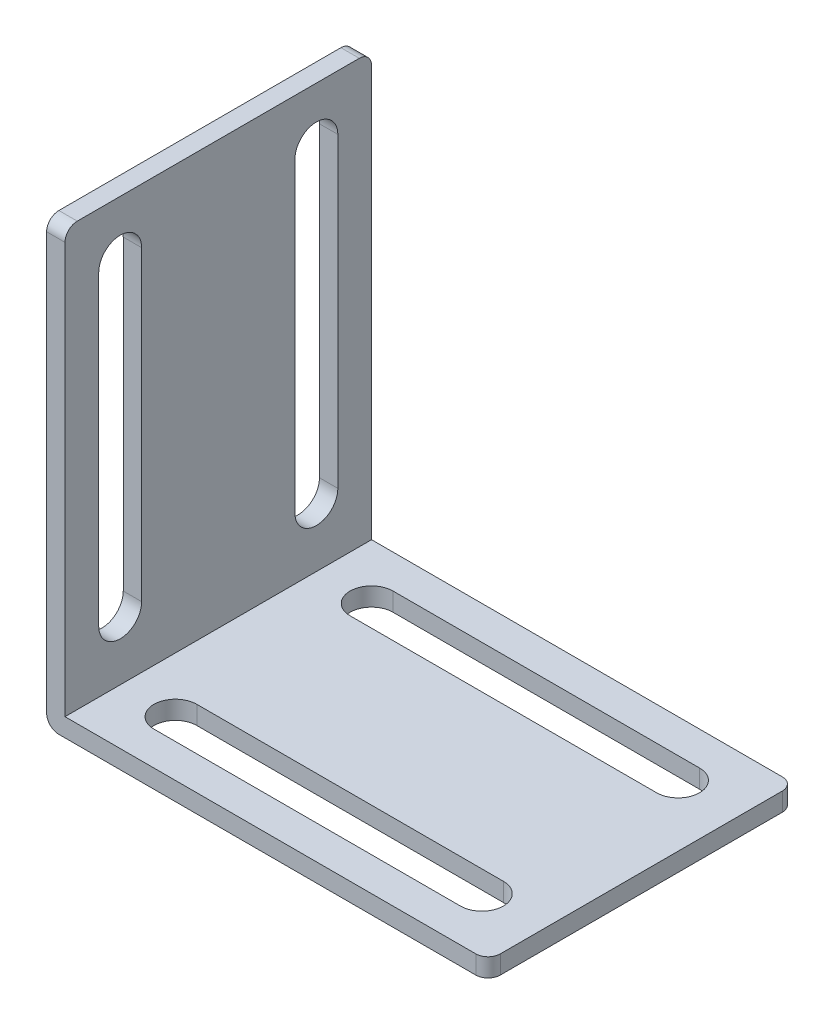
from build123d import *

# Parameters (mm, degrees)
SKETCH1_W           = 36
SKETCH1_H           = 25
BOSS_EXTRUDE1_DEPTH = 36
SKETCH2_W           = 34.5
SKETCH2_H           = 25
CUT_EXTRUDE1_DEPTH  = 34.5
FILLET1_R           = 1
CUT_EXTRUDE2_DEPTH  = 1.5
CUT_EXTRUDE3_DEPTH  = 1.5


with BuildPart() as part:
    # Sketch1 → Boss-Extrude1 (new body)
    with BuildSketch(Plane(origin=(0, 0, 0), x_dir=(1, 0, 0), z_dir=(0, 1, 0))):
        with Locations((18, 12.5)):
            Rectangle(SKETCH1_W, SKETCH1_H)
    extrude(amount=BOSS_EXTRUDE1_DEPTH)

    # Sketch2 → Cut-Extrude1 (cut)
    with BuildSketch(Plane(origin=(0, 36, 0), x_dir=(1, 0, 0), z_dir=(0, 1, 0))):
        with Locations((18.75, 12.5)):
            Rectangle(SKETCH2_W, SKETCH2_H)
    extrude(amount=-CUT_EXTRUDE1_DEPTH, mode=Mode.SUBTRACT)

    # Fillet1
    fillet1_edges = [part.edges().sort_by_distance(p)[0] for p in [
        (0.75, 36, -25),
        (36, 0.75, -25),
        (36, 0.75, 0),
        (0, 0, -12.5),
        (0.75, 36, 0),
    ]]
    fillet(fillet1_edges, radius=FILLET1_R)

    # Sketch3 → Cut-Extrude2 (cut)
    with BuildSketch(Plane(origin=(0, 1.5, 0), x_dir=(1, 0, 0), z_dir=(0, 1, 0))):
        with BuildLine():
            Line((31, 6.25), (6, 6.25))
            ThreePointArc((6, 6.25), (4.25, 4.5), (6, 2.75))
            Line((6, 2.75), (31, 2.75))
            ThreePointArc((31, 2.75), (32.75, 4.5), (31, 6.25))
        make_face()
        with BuildLine():
            Line((6, 18.75), (31, 18.75))
            ThreePointArc((31, 18.75), (32.75, 20.5), (31, 22.25))
            Line((31, 22.25), (6, 22.25))
            ThreePointArc((6, 22.25), (4.25, 20.5), (6, 18.75))
        make_face()
    extrude(amount=-CUT_EXTRUDE2_DEPTH, mode=Mode.SUBTRACT)

    # Sketch4 → Cut-Extrude3 (cut)
    with BuildSketch(Plane(origin=(1.5, 0, 0), x_dir=(0, 0, -1), z_dir=(1, 0, 0))):
        with BuildLine():
            Line((22.25, 6.5), (22.25, 31.5))
            ThreePointArc((22.25, 31.5), (20.5, 33.25), (18.75, 31.5))
            Line((18.75, 31.5), (18.75, 6.5))
            ThreePointArc((18.75, 6.5), (20.5, 4.75), (22.25, 6.5))
        make_face()
        with BuildLine():
            ThreePointArc((6.25, 31.5), (4.5, 33.25), (2.75, 31.5))
            Line((2.75, 31.5), (2.75, 6.5))
            ThreePointArc((2.75, 6.5), (4.5, 4.75), (6.25, 6.5))
            Line((6.25, 6.5), (6.25, 31.5))
        make_face()
    extrude(amount=-CUT_EXTRUDE3_DEPTH, mode=Mode.SUBTRACT)


solid = part.part
